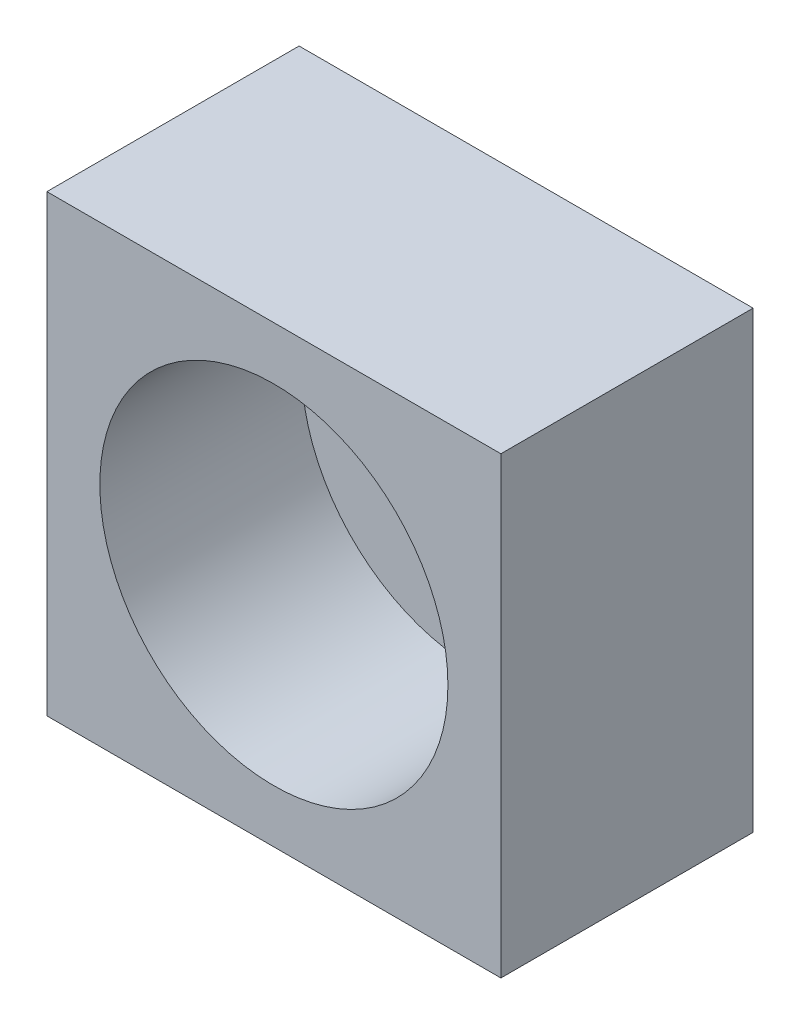
from build123d import *

# Parameters (mm, degrees)
CROQUIS1_W              = 18
CROQUIS1_H              = 18
SALIENTE_EXTRUIR1_DEPTH = 10
CROQUIS2_R              = 6.9
CORTAR_EXTRUIR1_DEPTH   = 8
CROQUIS3_R              = 2.75
CORTAR_EXTRUIR2_DEPTH   = 8


with BuildPart() as part:
    # Croquis1 → Saliente-Extruir1 (new body)
    with BuildSketch(Plane.XY):
        Rectangle(CROQUIS1_W, CROQUIS1_H)
    extrude(amount=SALIENTE_EXTRUIR1_DEPTH)

    # Croquis2 → Cortar-Extruir1 (cut)
    with BuildSketch(Plane.XY.offset(10)):
        Circle(CROQUIS2_R)
    extrude(amount=-CORTAR_EXTRUIR1_DEPTH, mode=Mode.SUBTRACT)

    # Croquis3 → Cortar-Extruir2 (cut)
    with BuildSketch(Plane.XY.offset(2)):
        Circle(CROQUIS3_R)
    extrude(amount=-CORTAR_EXTRUIR2_DEPTH, mode=Mode.SUBTRACT)


solid = part.part
